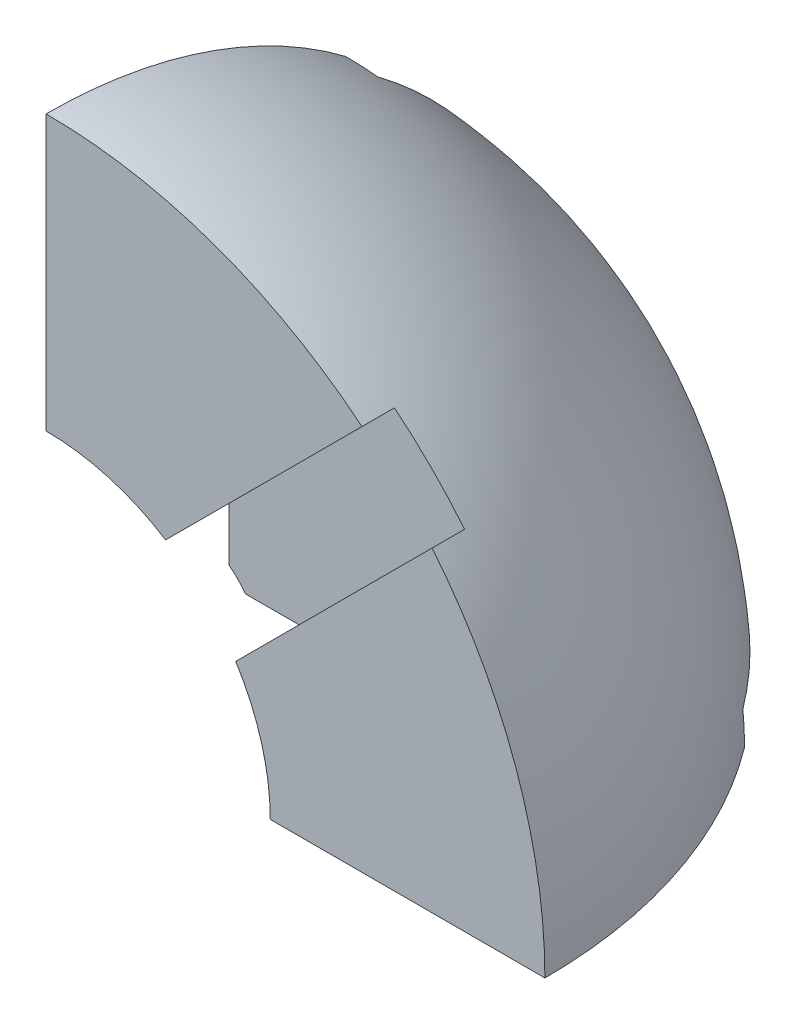
from build123d import *

# Parameters (mm, degrees)
REVOLVE1_ANGLE      = 90.0000000000002
SKETCH5_R           = 2.5000000000000013
CUT_EXTRUDE3_DEPTH  = 13.000000000000002
SKETCH6_R           = 2.5000000000000004
CUT_EXTRUDE4_DEPTH  = 13.000000000000002
SKETCH7_R           = 2.5000000000000013
CUT_EXTRUDE5_DEPTH  = 13.000000000000002
CUT_REVOLVE14_ANGLE = 90.0000000000002
CUT_EXTRUDE20_DEPTH = 0.9999999999999974
CUT_EXTRUDE24_DEPTH = 1
CUT_EXTRUDE25_DEPTH = 1


with BuildPart() as part:
    # Sketch4 → Revolve1 (revolve)
    with BuildSketch(Plane(origin=(0, 0, 0), x_dir=(1, 0, 0), z_dir=(0, 1, 0))):
        with BuildLine():
            Line((0, 0), (15, 0))
            ThreePointArc((15, 0), (10.606601717798213, 10.606601717798211), (0, 15))
            Line((0, 15), (0, 0))
        make_face()
    revolve(axis=Axis((0, 0, 0), (1, 0, 0)), revolution_arc=REVOLVE1_ANGLE)

    # Sketch5 → Cut-Extrude3 (cut)
    with BuildSketch(Plane.XY):
        with Locations((3, 3)):
            Circle(SKETCH5_R)
    extrude(amount=-CUT_EXTRUDE3_DEPTH, mode=Mode.SUBTRACT)

    # Sketch6 → Cut-Extrude4 (cut)
    with BuildSketch(Plane.ZY):
        with Locations((-3, 3)):
            Circle(SKETCH6_R)
    extrude(amount=-CUT_EXTRUDE4_DEPTH, mode=Mode.SUBTRACT)

    # Sketch7 → Cut-Extrude5 (cut)
    with BuildSketch(Plane.XZ):
        with Locations(Location((3, -3, 0), (0, 0, 270))):
            Circle(SKETCH7_R)
    extrude(amount=-CUT_EXTRUDE5_DEPTH, mode=Mode.SUBTRACT)

    # Sketch8 → Cut-Revolve14 (revolve, cut)
    with BuildSketch(Plane.XY):
        with BuildLine():
            ThreePointArc((4.767766952966368, 4.767766952966372), (2.580296881351315, 6.229387725907349), (0, 6.742640687119288))
            Line((0, 6.742640687119287), (0, 0))
            Line((0, 0), (6.742640687119288, 4.1e-16))
            ThreePointArc((6.742640687119288, 1.52e-15), (6.229387725907348, 2.5802968813513187), (4.767766952966368, 4.767766952966372))
        make_face()
        with BuildLine():
            ThreePointArc((5.500000000000002, 2.9999999999999996), (0.6903011687217822, 2.043291419087274), (4.767766952966367, 4.767766952966372))
            ThreePointArc((4.767766952966367, 4.767766952966372), (5.309698831278217, 3.9567085809127267), (5.500000000000002, 3))
        make_face(mode=Mode.SUBTRACT)
    revolve(axis=Axis((0, 0, 0), (0, 1, 3.49e-15)), revolution_arc=CUT_REVOLVE14_ANGLE, mode=Mode.SUBTRACT)

    # Sketch9 → Cut-Extrude20 (cut)
    with BuildSketch(Plane.XY):
        with BuildLine():
            ThreePointArc((11.6081867662439, 9.499999999999998), (10.606601717798215, 10.60660171779821), (9.500000000000005, 11.608186766243897))
            Line((9.500000000000005, 11.608186766243898), (11.608186766243902, 9.499999999999998))
        make_face()
        with BuildLine():
            Line((11.608186766243902, 9.499999999999998), (9.500000000000005, 11.608186766243898))
            Line((9.500000000000005, 11.608186766243898), (3.5956903599630037, 5.703877126206902))
            ThreePointArc((3.5956903599630796, 5.703877126206793), (4.207841503717712, 5.268517183723248), (4.767766952966372, 4.7677669529663715))
            ThreePointArc((4.767766952966372, 4.7677669529663715), (5.268517183723248, 4.207841503717712), (5.703877126206793, 3.5956903599630796))
            Line((5.703877126206905, 3.5956903599630046), (11.608186766243902, 9.499999999999998))
        make_face()
        with BuildLine():
            ThreePointArc((4.767766952966372, 4.7677669529663715), (4.207841503717712, 5.268517183723248), (3.5956903599630796, 5.703877126206793))
            Line((3.5956903599630037, 5.703877126206902), (-1.0540933831219501, 1.0540933831219519))
            Line((-1.0540933831219503, 1.054093383121952), (1.0540933831219486, -1.0540933831219486))
            Line((1.0540933831219483, -1.0540933831219483), (5.703877126206905, 3.5956903599630046))
            ThreePointArc((5.703877126206793, 3.5956903599630796), (5.268517183723248, 4.207841503717712), (4.767766952966372, 4.7677669529663715))
        make_face()
    extrude(amount=-CUT_EXTRUDE20_DEPTH, mode=Mode.SUBTRACT)

    # Sketch10 → Cut-Extrude24 (cut)
    with BuildSketch(Plane.ZY):
        with BuildLine():
            Line((-8.999999999999977, 11.999999999999961), (-11.999999999999998, 9.000000000000002))
            Line((-11.999999999999998, 9.000000000000002), (-6.025660362620837, 3.025660362620844))
            ThreePointArc((-6.025660362621033, 3.0256603626207323), (-5.466557614006139, 3.947144700710623), (-4.76776695296637, 4.767766952966371))
            ThreePointArc((-4.767766952966371, 4.767766952966371), (-3.947144700710626, 5.466557614006138), (-3.0256603626207372, 6.025660362621032))
            Line((-3.02566036262085, 6.025660362620837), (-8.999999999999977, 11.999999999999961))
        make_face()
        with BuildLine():
            ThreePointArc((-9.000000000000004, 11.999999999999996), (-10.606601717798211, 10.606601717798213), (-12, 9))
            Line((-11.999999999999998, 9.000000000000002), (-8.999999999999977, 11.999999999999961))
        make_face()
        with BuildLine():
            ThreePointArc((-4.76776695296637, 4.767766952966371), (-5.466557614006139, 3.947144700710623), (-6.025660362621033, 3.0256603626207323))
            Line((-6.025660362620837, 3.025660362620844), (-1.4999999999999947, -1.4999999999999947))
            Line((-1.4999999999999944, -1.4999999999999944), (1.499999999999994, 1.4999999999999944))
            Line((1.4999999999999947, 1.4999999999999947), (-3.02566036262085, 6.025660362620837))
            ThreePointArc((-3.0256603626207372, 6.025660362621032), (-3.947144700710626, 5.466557614006138), (-4.767766952966371, 4.767766952966371))
        make_face()
    extrude(amount=-CUT_EXTRUDE24_DEPTH, mode=Mode.SUBTRACT)

    # Sketch11 → Cut-Extrude25 (cut)
    with BuildSketch(Plane.XZ):
        with BuildLine():
            Line((11.999999999999996, -9.000000000000002), (9.000000000000002, -11.999999999999998))
            ThreePointArc((8.999999999999996, -12.000000000000002), (10.60660171779821, -10.606601717798215), (11.999999999999998, -9.000000000000002))
        make_face()
        with BuildLine():
            Line((3.0256603626208403, -6.025660362620841), (9.000000000000002, -11.999999999999998))
            Line((9.000000000000002, -11.999999999999998), (11.999999999999996, -9.000000000000002))
            Line((11.999999999999996, -9.000000000000002), (6.02566036262084, -3.0256603626208403))
            ThreePointArc((6.025660362621034, -3.025660362620727), (5.466557614006142, -3.9471447007106204), (4.767766952966371, -4.767766952966369))
            ThreePointArc((4.7677669529663715, -4.767766952966372), (3.9471447007106226, -5.466557614006144), (3.0256603626207275, -6.025660362621036))
        make_face()
        with BuildLine():
            Line((-1.5000000000000036, -1.5), (3.0256603626208403, -6.025660362620841))
            ThreePointArc((3.0256603626207275, -6.025660362621036), (3.9471447007106226, -5.466557614006144), (4.7677669529663715, -4.767766952966372))
            ThreePointArc((4.767766952966371, -4.767766952966369), (5.466557614006142, -3.9471447007106204), (6.025660362621034, -3.025660362620727))
            Line((6.02566036262084, -3.0256603626208403), (1.5, 1.5000000000000036))
            Line((1.4999999999999996, 1.5000000000000036), (-1.500000000000003, -1.4999999999999996))
        make_face()
    extrude(amount=-CUT_EXTRUDE25_DEPTH, mode=Mode.SUBTRACT)


solid = part.part
